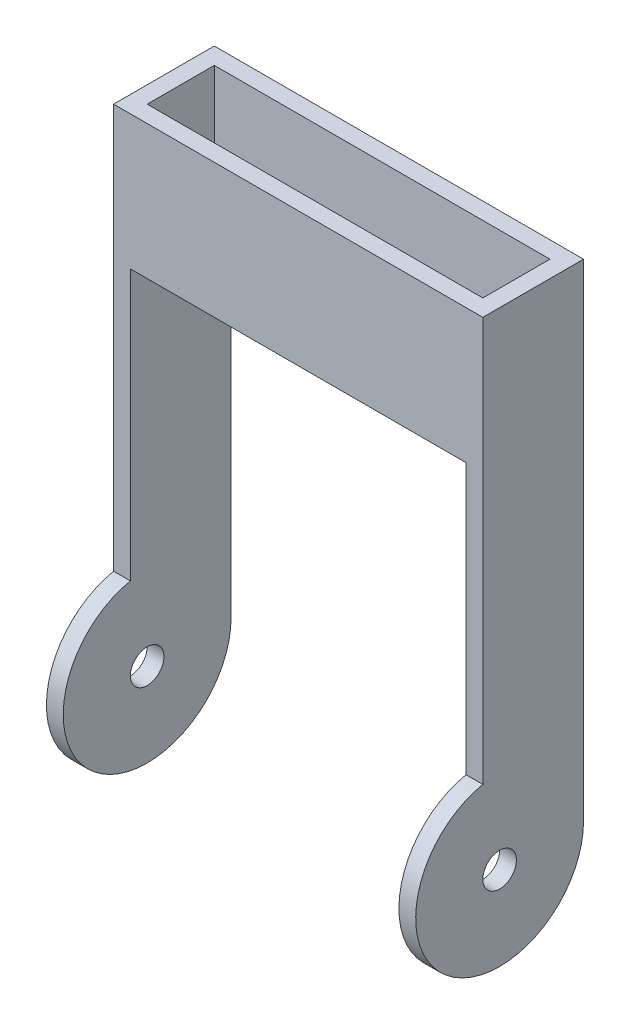
from build123d import *

# Parameters (mm, degrees)
PROBEPROFILE_W      = 69.85
PROBEPROFILE_H      = 19.05
PROBEPROFILE_W_2    = 63.5
PROBEPROFILE_H_2    = 12.7
EXTRUDE_THIN1_DEPTH = 25.4
SKETCH2_R           = 15.875
BOSS_EXTRUDE1_DEPTH = 34.925
SKETCH2_2_R         = 15.875
CUT_EXTRUDE1_DEPTH  = 31.75
SKETCH3_W           = 3.175
SKETCH3_H           = 19.05
BOSS_EXTRUDE2_DEPTH = 66.675
CUT_EXTRUDE2_START  = -69.85
SKETCH4_R           = 3.175
CUT_EXTRUDE2_DEPTH  = 69.85


with BuildPart() as part:
    # ProbeProfile → Extrude-Thin1 (new body)
    with BuildSketch(Plane(origin=(0, 0, 0), x_dir=(1, 0, 0), z_dir=(0, 1, 0))):
        Rectangle(PROBEPROFILE_W, PROBEPROFILE_H)
        Rectangle(PROBEPROFILE_W_2, PROBEPROFILE_H_2, mode=Mode.SUBTRACT)
    extrude(amount=EXTRUDE_THIN1_DEPTH)



with BuildPart() as body_2:
    # Sketch2 → Boss-Extrude1 (new body, symmetric)
    with BuildSketch(Plane(origin=(0, 0, 0), x_dir=(0, 0, -1), z_dir=(1, 0, 0))):
        with Locations((-6.35, -66.675)):
            Circle(SKETCH2_R)
    extrude(amount=BOSS_EXTRUDE1_DEPTH, both=True)

    # Sketch2_2 → Cut-Extrude1 (cut, symmetric)
    with BuildSketch(Plane(origin=(0, 0, 0), x_dir=(0, 0, -1), z_dir=(1, 0, 0))):
        with Locations((-6.35, -66.675)):
            Circle(SKETCH2_2_R)
    extrude(amount=CUT_EXTRUDE1_DEPTH, both=True, mode=Mode.SUBTRACT)


with BuildPart() as part_1:
    add(part.part)

    add(body_2.part)  # Boss-Extrude2 merges body 2
    # Sketch3 → Boss-Extrude2 (add)
    with BuildSketch(Plane.XZ):
        with Locations((33.3375, 0)):
            Rectangle(SKETCH3_W, SKETCH3_H)
        with Locations((-33.3375, 0)):
            Rectangle(SKETCH3_W, SKETCH3_H)
    extrude(amount=BOSS_EXTRUDE2_DEPTH)

    # Sketch4 → Cut-Extrude2 (cut)
    with BuildSketch(Plane.ZY.offset(34.925).offset(CUT_EXTRUDE2_START)):
        with Locations((6.35, -66.675)):
            Circle(SKETCH4_R)
    extrude(amount=CUT_EXTRUDE2_DEPTH, mode=Mode.SUBTRACT)


solid = part_1.part
